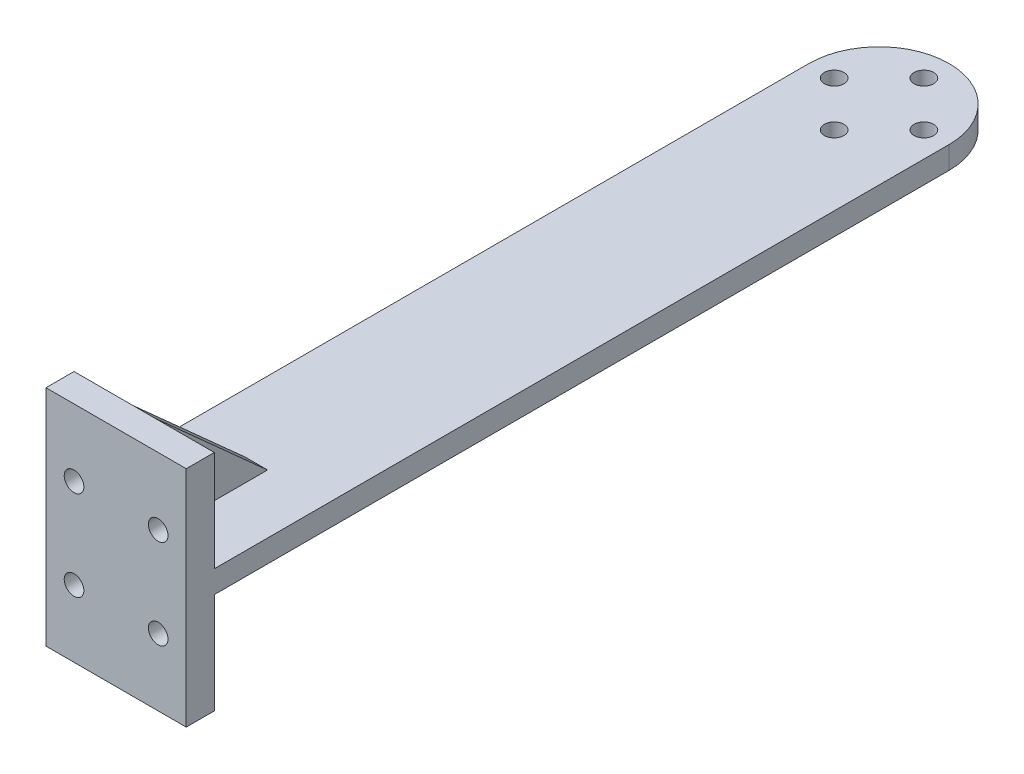
from build123d import *

# Parameters (mm, degrees)
BOSS_EXTRUDE1_DEPTH = 4
SKETCH2_W           = 25
SKETCH2_H           = 5
BOSS_EXTRUDE2_DEPTH = 17.95
SKETCH3_R           = 1.75
CUT_EXTRUDE1_DEPTH  = 6
SKETCH4_W           = 4
SKETCH4_H           = 17.95
BOSS_EXTRUDE3_DEPTH = 20
CUT_EXTRUDE2_DEPTH  = 15.5
SKETCH6_R           = 1.75
CUT_EXTRUDE3_DEPTH  = 22.95


with BuildPart() as part:
    # Sketch1 → Boss-Extrude1 (new body)
    with BuildSketch(Plane(origin=(0, 0, 0), x_dir=(1, 0, 0), z_dir=(0, 1, 0))):
        with BuildLine():
            Line((0, 0), (25, 0))
            Line((25, 0), (25, 136))
            ThreePointArc((25, 136), (12.5, 148.5), (0, 136))
            Line((0, 136), (0, 0))
        make_face()
    extrude(amount=BOSS_EXTRUDE1_DEPTH)

    # Sketch2 → Boss-Extrude2 (add)
    with BuildSketch(Plane(origin=(0, 4, 0), x_dir=(1, 0, 0), z_dir=(0, 1, 0))):
        with Locations((12.5, 2.5)):
            Rectangle(SKETCH2_W, SKETCH2_H)
    boss_extrude2 = extrude(amount=BOSS_EXTRUDE2_DEPTH)

    # Sketch3 → Cut-Extrude1 (cut, through all)
    with BuildSketch(Plane(origin=(0, 0, -5), x_dir=(-1, 0, 0), z_dir=(0, 0, -1))):
        with Locations((-20, 10)):
            Circle(SKETCH3_R)
        with Locations((-5, 10)):
            Circle(SKETCH3_R)
    cut_extrude1 = extrude(amount=-CUT_EXTRUDE1_DEPTH, mode=Mode.SUBTRACT)

    # Sketch4 → Boss-Extrude3 (add)
    with BuildSketch(Plane(origin=(0, 0, -5), x_dir=(-1, 0, 0), z_dir=(0, 0, -1))):
        with Locations((-12.5, 12.975)):
            Rectangle(SKETCH4_W, SKETCH4_H)
    boss_extrude3 = extrude(amount=BOSS_EXTRUDE3_DEPTH)

    # Sketch5 → Cut-Extrude2 (cut, through all)
    with BuildSketch(Plane(origin=(14.5, 0, 0), x_dir=(0, 0, -1), z_dir=(1, 0, 0))):
        Polygon((25, 4), (5, 21.95), (25, 21.95), align=None)
    cut_extrude2 = extrude(amount=-CUT_EXTRUDE2_DEPTH, mode=Mode.SUBTRACT)

    # Mirror1: Boss-Extrude2, Cut-Extrude1, Boss-Extrude3, Cut-Extrude2 across plane
    add(boss_extrude2.mirror(Plane.ZX.offset(2)))
    add(cut_extrude1.mirror(Plane.ZX.offset(2)), mode=Mode.SUBTRACT)
    add(boss_extrude3.mirror(Plane.ZX.offset(2)))
    add(cut_extrude2.mirror(Plane.ZX.offset(2)), mode=Mode.SUBTRACT)

    # Sketch6 → Cut-Extrude3 (cut, through all)
    with BuildSketch(Plane(origin=(0, 4, 0), x_dir=(1, 0, 0), z_dir=(0, 1, 0))):
        with Locations((12.5, 144)):
            Circle(SKETCH6_R)
        with Locations((20.5, 136)):
            Circle(SKETCH6_R)
        with Locations((12.5, 128)):
            Circle(SKETCH6_R)
        with Locations((4.5, 136)):
            Circle(SKETCH6_R)
    extrude(amount=-CUT_EXTRUDE3_DEPTH, mode=Mode.SUBTRACT)


solid = part.part
